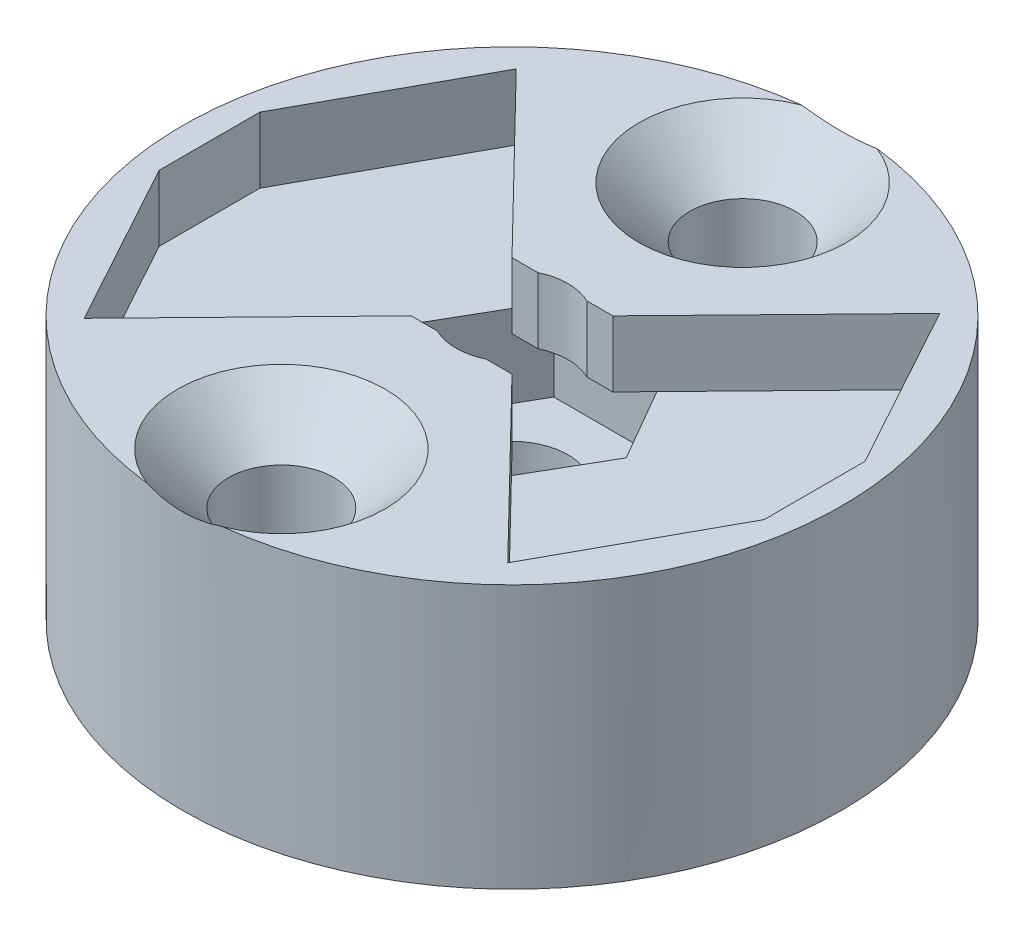
from build123d import *

# Parameters (mm, degrees)
SKETCH1_R                                           = 10
BOSS_EXTRUDE1_DEPTH                                 = 6
CUT_EXTRUDE4_DEPTH                                  = 2.5
SKETCH9_R                                           = 10
BOSS_EXTRUDE2_DEPTH                                 = 2
CSK_FOR_M3_COUNTERSUNK_FLAT_HEAD_SCREW2_D           = 3.2
CSK_FOR_M3_COUNTERSUNK_FLAT_HEAD_SCREW2_CSINK_D     = 6.3
CSK_FOR_M3_COUNTERSUNK_FLAT_HEAD_SCREW2_CSINK_ANGLE = 90
CUT_EXTRUDE6_DEPTH                                  = 2
SKETCH18_R                                          = 1.7
CUT_EXTRUDE8_DEPTH                                  = 9


with BuildPart() as part:
    # Sketch1 → Boss-Extrude1 (new body)
    with BuildSketch(Plane(origin=(0, 0, 0), x_dir=(1, 0, 0), z_dir=(0, 1, 0))):
        Circle(SKETCH1_R)
    extrude(amount=BOSS_EXTRUDE1_DEPTH)

    # Sketch8 → Cut-Extrude4 (cut)
    with BuildSketch(Plane(origin=(0, 6, 0), x_dir=(1, 0, 0), z_dir=(0, 1, 0))):
        Polygon((3.464101615, 0), (1.732050808, 3), (-1.732050808, 3), (-3.464101615, 0), (-1.732050808, -3), (1.732050808, -3), align=None)
    extrude(amount=-CUT_EXTRUDE4_DEPTH, mode=Mode.SUBTRACT)

    # Sketch9 → Boss-Extrude2 (add)
    with BuildSketch(Plane(origin=(0, 6, 0), x_dir=(1, 0, 0), z_dir=(0, 1, 0))):
        Circle(SKETCH9_R)
    extrude(amount=BOSS_EXTRUDE2_DEPTH)

    # CSK for M3 Countersunk Flat Head Screw2 (through all)
    with Locations(Plane(origin=(0, 8, 0), x_dir=(1, 0, 0), z_dir=(0, 1, 0))):
        with Locations((0, 7), (0, -7)):
            CounterSinkHole(CSK_FOR_M3_COUNTERSUNK_FLAT_HEAD_SCREW2_D / 2, CSK_FOR_M3_COUNTERSUNK_FLAT_HEAD_SCREW2_CSINK_D / 2, counter_sink_angle=CSK_FOR_M3_COUNTERSUNK_FLAT_HEAD_SCREW2_CSINK_ANGLE)

    # Sketch16 → Cut-Extrude6 (cut)
    with BuildSketch(Plane(origin=(0, 8, 0), x_dir=(1, 0, 0), z_dir=(0, 1, 0))):
        Polygon((-6.426401471, 6.555437753), (-9.18, 1.53), (-9.18, -1.53), (-6.426401471, -6.555437753), (-1.53, -1.53), (1.53, -1.53), (6.426401471, -6.555437753), (9.18, -1.53), (9.18, 1.53), (6.426401471, 6.555437753), (1.53, 1.53), (-1.53, 1.53), align=None)
    extrude(amount=-CUT_EXTRUDE6_DEPTH, mode=Mode.SUBTRACT)

    # Sketch18 → Cut-Extrude8 (cut)
    with BuildSketch(Plane(origin=(0, 8, 0), x_dir=(1, 0, 0), z_dir=(0, 1, 0))):
        Circle(SKETCH18_R)
    extrude(amount=-CUT_EXTRUDE8_DEPTH, mode=Mode.SUBTRACT)


solid = part.part
